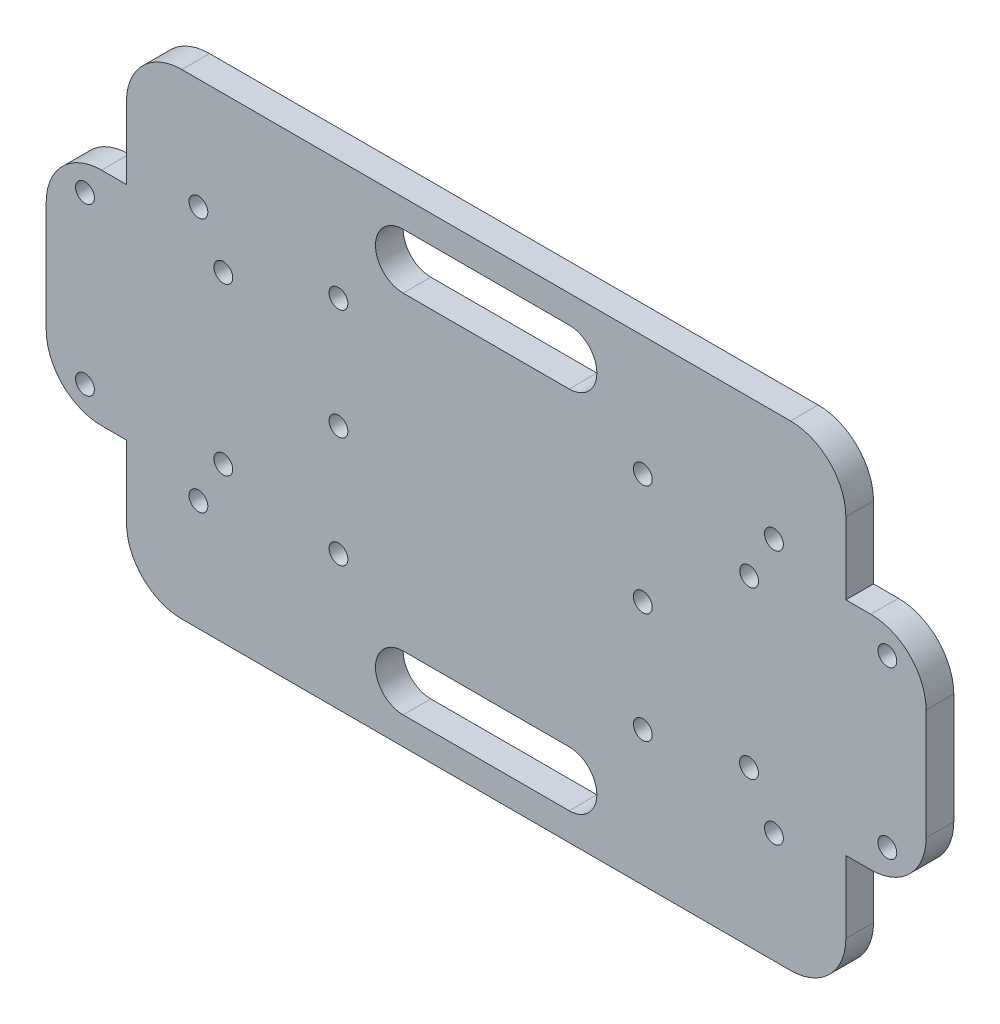
from build123d import *

# Parameters (mm, degrees)
BOSS_EXTRUDE2_DEPTH = 5
SKETCH3_R           = 1.7
CUT_EXTRUDE1_DEPTH  = 5


with BuildPart() as part:
    # Sketch1 → Boss-Extrude2 (new body)
    with BuildSketch(Plane.XY):
        with BuildLine():
            Line((-65, -20), (-65, -33))
            ThreePointArc((-65, -33), (-62.071067812, -40.071067812), (-55, -43))
            Line((-55, -43), (55, -43))
            ThreePointArc((55, -43), (62.071067812, -40.071067812), (65, -33))
            Line((65, -33), (65, -20))
            Line((65, -20), (69.5, -20))
            ThreePointArc((69.5, -20), (76.571067812, -17.071067812), (79.5, -10))
            Line((79.5, -10), (79.5, 10))
            ThreePointArc((79.5, 10), (76.571067812, 17.071067812), (69.5, 20))
            Line((69.5, 20), (65, 20))
            Line((65, 20), (65, 33))
            ThreePointArc((65, 33), (62.071067812, 40.071067812), (55, 43))
            Line((55, 43), (-55, 43))
            ThreePointArc((-55, 43), (-62.071067812, 40.071067812), (-65, 33))
            Line((-65, 33), (-65, 20))
            Line((-65, 20), (-69.5, 20))
            ThreePointArc((-69.5, 20), (-76.571067812, 17.071067812), (-79.5, 10))
            Line((-79.5, 10), (-79.5, -10))
            ThreePointArc((-79.5, -10), (-76.571067812, -17.071067812), (-69.5, -20))
            Line((-69.5, -20), (-65, -20))
        make_face()
    extrude(amount=BOSS_EXTRUDE2_DEPTH)

    # Sketch3 → Cut-Extrude1 (cut)
    with BuildSketch(Plane.XY.offset(5)):
        with Locations((-47.5, -15)):
            Circle(SKETCH3_R)
        with Locations((-47.5, 15)):
            Circle(SKETCH3_R)
        with Locations((72.5, 15)):
            Circle(SKETCH3_R)
        with Locations((47.52365162, 15)):
            Circle(SKETCH3_R)
        with Locations((72.5, -15)):
            Circle(SKETCH3_R)
        with Locations((47.5, -15)):
            Circle(SKETCH3_R)
        with BuildLine():
            Line((15, 38), (-15, 38))
            ThreePointArc((-15, 38), (-20, 33), (-15, 28))
            Line((-15, 28), (15, 28))
            ThreePointArc((15, 28), (20, 33), (15, 38))
        make_face()
        with BuildLine():
            Line((15, -28), (-15, -28))
            ThreePointArc((-15, -28), (-20, -33), (-15, -38))
            Line((-15, -38), (15, -38))
            ThreePointArc((15, -38), (20, -33), (15, -28))
        make_face()
        with Locations((-72.5, -15)):
            Circle(SKETCH3_R)
        with Locations((-72.5, 15)):
            Circle(SKETCH3_R)
        with Locations((-26.692902898, 21.354322319)):
            Circle(SKETCH3_R)
        with Locations((-26.692902898, 1.354322319)):
            Circle(SKETCH3_R)
        with Locations((-26.692902898, -18.645677681)):
            Circle(SKETCH3_R)
        with Locations((28.307097102, -18.645677681)):
            Circle(SKETCH3_R)
        with Locations((28.307097102, 1.354322319)):
            Circle(SKETCH3_R)
        with Locations((28.307097102, 21.354322319)):
            Circle(SKETCH3_R)
        with Locations((-52, 23)):
            Circle(SKETCH3_R)
        with Locations((-52, -23)):
            Circle(SKETCH3_R)
        with Locations((52, -23)):
            Circle(SKETCH3_R)
        with Locations((52, 23)):
            Circle(SKETCH3_R)
    extrude(amount=-CUT_EXTRUDE1_DEPTH, mode=Mode.SUBTRACT)


solid = part.part
